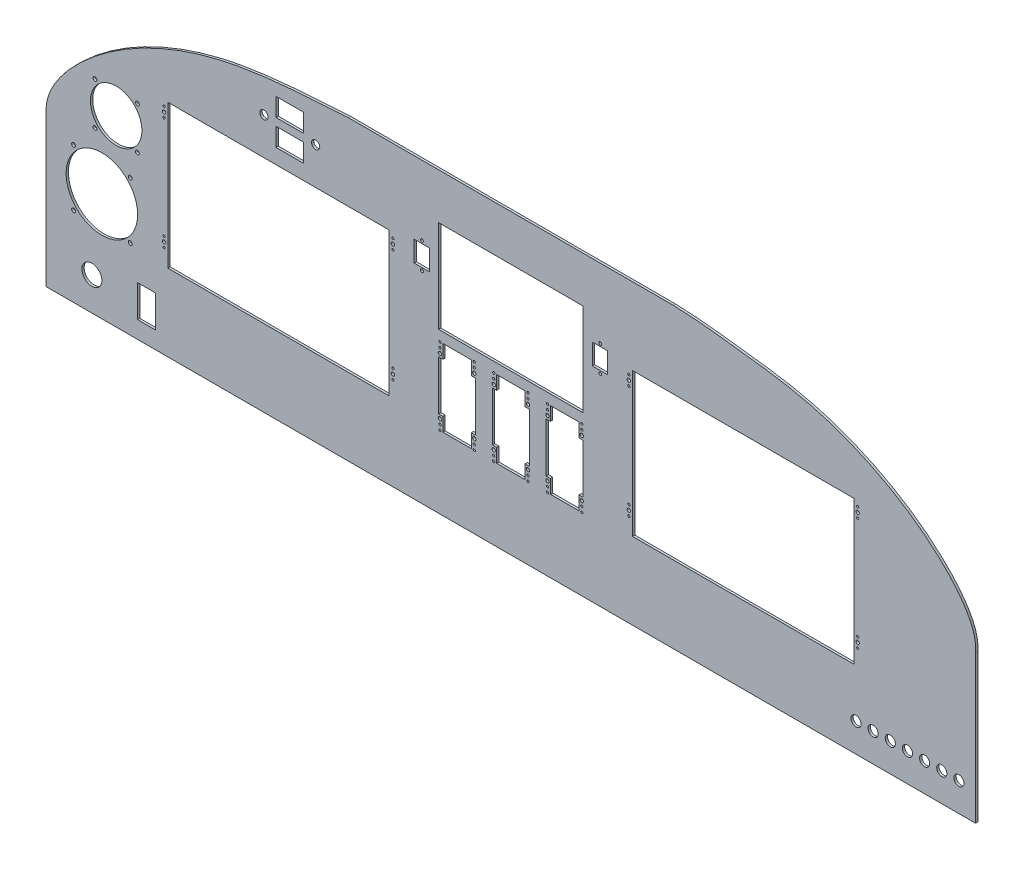
from build123d import *

# Parameters (mm, degrees)
BOSS_EXTRUDE1_DEPTH = 2.54
CUTOUTS_W           = 30.48
CUTOUTS_H           = 20.32
CUTOUTS_W_2         = 160.528
CUTOUTS_H_2         = 102.616
CUTOUTS_W_3         = 19.812
CUTOUTS_H_3         = 35.56
CUTOUTS_R           = 11.1125
CUTOUTS_R_2         = 4.572
CUTOUTS_R_3         = 2.159
CUTOUTS_R_4         = 28.575
CUTOUTS_R_5         = 5.6515
CUTOUTS_W_4         = 17.145
CUTOUTS_H_4         = 22.987
CUTOUTS_R_6         = 1.63195
CUTOUTS_W_5         = 245.872
CUTOUTS_H_5         = 159.512
CUTOUTS_R_7         = 1.905
CUTOUTS_R_8         = 1.2446
CUTOUTS_R_9         = 39.6875
CUTOUTS_R_10        = 1.2192
CUT_EXTRUDE2_DEPTH  = 35.56


with BuildPart() as part:
    # Sketch1 → Boss-Extrude1 (new body)
    with BuildSketch(Plane.XY):
        with BuildLine():
            Line((811.906883507, -110.092431215), (-219.968116493, -110.092431215))
            Line((-219.968116493, -110.092431215), (-219.968116493, 55.007568785))
            add(Edge.make_bspline(
                [(115.824387472, 220.107568785), (89.94779281, 218.395320997), (43.792953929, 216.125779032), (-34.024932947, 205.365785995), (-112.059127747, 177.930529871), (-173.680661768, 135.400924588), (-210.488772946, 93.724502924), (-221.117388715, 69.332207309), (-219.968116493, 55.007568785)],
                knots=[0, 0, 0, 0, 0.194074051, 0.345724161, 0.586618586, 0.805906469, 0.897735543, 1, 1, 1, 1], degree=3))
            Line((115.824387472, 220.107568785), (476.114379542, 220.107568785))
            add(Edge.make_bspline(
                [(476.114379542, 220.107568785), (502.136878249, 219.397773539), (548.004712859, 213.606121414), (625.995036096, 204.124676274), (703.983564018, 176.21064107), (765.616180751, 133.801166892), (802.42990745, 92.104336018), (813.0587373, 67.704986995), (811.906883507, 53.369400067)],
                knots=[0, 0, 0, 0, 0.194361161, 0.345944213, 0.586732117, 0.805923033, 0.897711501, 1, 1, 1, 1], degree=3))
            Line((811.906883507, 53.369400067), (811.906883507, -110.092431215))
        make_face()
    extrude(amount=BOSS_EXTRUDE1_DEPTH)

    # Cutouts → Cut-Extrude2 (cut)
    with BuildSketch(Plane.XY.offset(2.54)):
        with Locations((50.503675603, 190.30565476)):
            Rectangle(CUTOUTS_W, CUTOUTS_H)
        with Locations((295.969383507, 117.999568785)):
            Rectangle(CUTOUTS_W_2, CUTOUTS_H_2)
        with Locations((50.503675603, 161.53534255)):
            Rectangle(CUTOUTS_W, CUTOUTS_H)
        with Locations((-108.462116493, -73.262431215)):
            Rectangle(CUTOUTS_W_3, CUTOUTS_H_3)
        with Locations((-169.168116493, -73.262431215)):
            Circle(CUTOUTS_R)
        with Locations((21.770284207, 175.920498655)):
            Circle(CUTOUTS_R_2)
        with Locations((79.237067, 175.920498655)):
            Circle(CUTOUTS_R_2)
        with Locations((-118.654271041, 69.534396467)):
            Circle(CUTOUTS_R_3)
        with Locations((-165.800615676, 69.534396467)):
            Circle(CUTOUTS_R_3)
        with Locations((-165.800615676, 116.680741103)):
            Circle(CUTOUTS_R_3)
        with Locations((-118.654271041, 116.680741103)):
            Circle(CUTOUTS_R_3)
        with Locations((-142.227443359, 93.107568785)):
            Circle(CUTOUTS_R_4)
        with Locations((679.094675241, -78.342431215)):
            Circle(CUTOUTS_R_5)
        with Locations((698.144675241, -78.342431215)):
            Circle(CUTOUTS_R_5)
        with Locations((717.194675241, -78.342431215)):
            Circle(CUTOUTS_R_5)
        with Locations((736.244675241, -78.342431215)):
            Circle(CUTOUTS_R_5)
        with Locations((755.294675241, -78.342431215)):
            Circle(CUTOUTS_R_5)
        with Locations((774.344675241, -78.342431215)):
            Circle(CUTOUTS_R_5)
        with Locations((793.394675241, -78.342431215)):
            Circle(CUTOUTS_R_5)
        with Locations((197.020508507, 128.350068785)):
            Rectangle(CUTOUTS_W_4, CUTOUTS_H_4)
        with Locations((197.298702847, 142.853468785)):
            Circle(CUTOUTS_R_6)
        with Locations((197.298702847, 113.846668785)):
            Circle(CUTOUTS_R_6)
        with Locations((38.000633507, 55.007568785)):
            Rectangle(CUTOUTS_W_5, CUTOUTS_H_5)
        with Locations((-88.999366493, 123.333568785)):
            Circle(CUTOUTS_R_7)
        with Locations((-88.999366493, 117.783568785)):
            Circle(CUTOUTS_R_8)
        with Locations((-88.999366493, -1.634431215)):
            Circle(CUTOUTS_R_7)
        with Locations((-88.999366493, -7.184431215)):
            Circle(CUTOUTS_R_8)
        with Locations((165.000633507, -1.634431215)):
            Circle(CUTOUTS_R_7)
        with Locations((165.000633507, -7.184431215)):
            Circle(CUTOUTS_R_8)
        with Locations((165.000633507, 123.333568785)):
            Circle(CUTOUTS_R_7)
        with Locations((-88.999366493, 128.883568785)):
            Circle(CUTOUTS_R_8)
        with Locations((-88.999366493, 3.915568785)):
            Circle(CUTOUTS_R_8)
        with Locations((165.000633507, 128.883568785)):
            Circle(CUTOUTS_R_8)
        with Locations((165.000633507, 117.783568785)):
            Circle(CUTOUTS_R_8)
        with Locations((165.000633507, 3.915568785)):
            Circle(CUTOUTS_R_8)
        with Locations((-126.646828725, -21.480629672)):
            Circle(CUTOUTS_R_3)
        with Locations((-158.079328725, 9.951870328)):
            Circle(CUTOUTS_R_9)
        with Locations((-189.511828725, -21.480629672)):
            Circle(CUTOUTS_R_3)
        with Locations((-126.646828725, 41.384370328)):
            Circle(CUTOUTS_R_3)
        with Locations((-189.511828725, 41.384370328)):
            Circle(CUTOUTS_R_3)
        Polygon((280.221383507, -29.828431215), (311.717383507, -29.828431215), (311.717383507, -14.588431215), (316.543383507, -14.588431215), (316.543383507, 40.275568785), (311.717383507, 40.275568785), (311.717383507, 55.515568785), (280.221383507, 55.515568785), (280.221383507, 40.275568785), (275.395383507, 40.275568785), (275.395383507, -14.588431215), (280.221383507, -14.588431215), align=None)
        with Locations((315.019383507, 44.237968785)):
            Circle(CUTOUTS_R_7)
        with Locations((276.919383507, -18.550831215)):
            Circle(CUTOUTS_R_7)
        with Locations((315.019383507, -18.550831215)):
            Circle(CUTOUTS_R_7)
        with Locations((315.019383507, 49.775168785)):
            Circle(CUTOUTS_R_10)
        with Locations((315.019383507, 55.337768785)):
            Circle(CUTOUTS_R_10)
        with Locations((276.919383507, 44.237968785)):
            Circle(CUTOUTS_R_7)
        with Locations((276.919383507, 49.775168785)):
            Circle(CUTOUTS_R_10)
        with Locations((276.919383507, 55.337768785)):
            Circle(CUTOUTS_R_10)
        with Locations((276.919383507, -24.088031215)):
            Circle(CUTOUTS_R_10)
        with Locations((276.919383507, -29.650631215)):
            Circle(CUTOUTS_R_10)
        with Locations((315.019383507, -24.088031215)):
            Circle(CUTOUTS_R_10)
        with Locations((315.019383507, -29.650631215)):
            Circle(CUTOUTS_R_10)
        Polygon((220.531383507, -29.828431215), (252.027383507, -29.828431215), (252.027383507, -14.588431215), (256.853383507, -14.588431215), (256.853383507, 40.275568785), (252.027383507, 40.275568785), (252.027383507, 55.515568785), (220.531383507, 55.515568785), (220.531383507, 40.275568785), (215.705383507, 40.275568785), (215.705383507, -14.588431215), (220.531383507, -14.588431215), align=None)
        with Locations((255.329383507, 44.237968785)):
            Circle(CUTOUTS_R_7)
        with Locations((217.229383507, -18.550831215)):
            Circle(CUTOUTS_R_7)
        with Locations((255.329383507, -18.550831215)):
            Circle(CUTOUTS_R_7)
        with Locations((255.329383507, 49.775168785)):
            Circle(CUTOUTS_R_10)
        with Locations((255.329383507, 55.337768785)):
            Circle(CUTOUTS_R_10)
        with Locations((217.229383507, 44.237968785)):
            Circle(CUTOUTS_R_7)
        with Locations((217.229383507, 49.775168785)):
            Circle(CUTOUTS_R_10)
        with Locations((217.229383507, 55.337768785)):
            Circle(CUTOUTS_R_10)
        with Locations((217.229383507, -24.088031215)):
            Circle(CUTOUTS_R_10)
        with Locations((217.229383507, -29.650631215)):
            Circle(CUTOUTS_R_10)
        with Locations((255.329383507, -24.088031215)):
            Circle(CUTOUTS_R_10)
        with Locations((255.329383507, -29.650631215)):
            Circle(CUTOUTS_R_10)
        with Locations((553.938133507, 55.007568785)):
            Rectangle(CUTOUTS_W_5, CUTOUTS_H_5)
        with Locations((426.938133507, 123.333568785)):
            Circle(CUTOUTS_R_7)
        with Locations((426.938133507, 117.783568785)):
            Circle(CUTOUTS_R_8)
        with Locations((426.938133507, -1.634431215)):
            Circle(CUTOUTS_R_7)
        with Locations((426.938133507, -7.184431215)):
            Circle(CUTOUTS_R_8)
        with Locations((680.938133507, -1.634431215)):
            Circle(CUTOUTS_R_7)
        with Locations((680.938133507, -7.184431215)):
            Circle(CUTOUTS_R_8)
        with Locations((680.938133507, 123.333568785)):
            Circle(CUTOUTS_R_7)
        with Locations((426.938133507, 128.883568785)):
            Circle(CUTOUTS_R_8)
        with Locations((426.938133507, 3.915568785)):
            Circle(CUTOUTS_R_8)
        with Locations((680.938133507, 128.883568785)):
            Circle(CUTOUTS_R_8)
        with Locations((680.938133507, 117.783568785)):
            Circle(CUTOUTS_R_8)
        with Locations((680.938133507, 3.915568785)):
            Circle(CUTOUTS_R_8)
        with Locations((394.918258507, 128.350068785)):
            Rectangle(CUTOUTS_W_4, CUTOUTS_H_4)
        with Locations((395.196452847, 142.853468785)):
            Circle(CUTOUTS_R_6)
        with Locations((395.196452847, 113.846668785)):
            Circle(CUTOUTS_R_6)
        Polygon((339.911383507, -29.828431215), (371.407383507, -29.828431215), (371.407383507, -14.588431215), (376.233383507, -14.588431215), (376.233383507, 40.275568785), (371.407383507, 40.275568785), (371.407383507, 55.515568785), (339.911383507, 55.515568785), (339.911383507, 40.275568785), (335.085383507, 40.275568785), (335.085383507, -14.588431215), (339.911383507, -14.588431215), align=None)
        with Locations((374.709383507, 44.237968785)):
            Circle(CUTOUTS_R_7)
        with Locations((336.609383507, -18.550831215)):
            Circle(CUTOUTS_R_7)
        with Locations((374.709383507, -18.550831215)):
            Circle(CUTOUTS_R_7)
        with Locations((374.709383507, 49.775168785)):
            Circle(CUTOUTS_R_10)
        with Locations((374.709383507, 55.337768785)):
            Circle(CUTOUTS_R_10)
        with Locations((336.609383507, 44.237968785)):
            Circle(CUTOUTS_R_7)
        with Locations((336.609383507, 49.775168785)):
            Circle(CUTOUTS_R_10)
        with Locations((336.609383507, 55.337768785)):
            Circle(CUTOUTS_R_10)
        with Locations((336.609383507, -24.088031215)):
            Circle(CUTOUTS_R_10)
        with Locations((336.609383507, -29.650631215)):
            Circle(CUTOUTS_R_10)
        with Locations((374.709383507, -24.088031215)):
            Circle(CUTOUTS_R_10)
        with Locations((374.709383507, -29.650631215)):
            Circle(CUTOUTS_R_10)
    extrude(amount=-CUT_EXTRUDE2_DEPTH, mode=Mode.SUBTRACT)


solid = part.part
